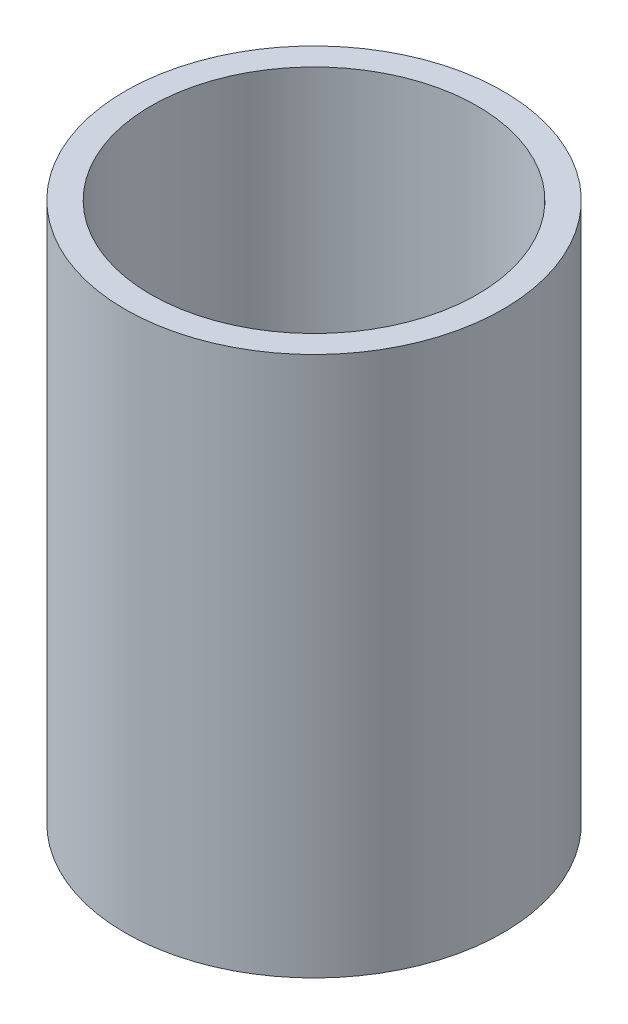
from build123d import *

# Parameters (mm, degrees)
SKETCH1_W = 6.35
SKETCH1_H = 133.35


with BuildPart() as part:
    # Sketch1 → Revolve1 (revolve)
    with BuildSketch(Plane.XY):
        with Locations((-43.4975, -21.057365567)):
            Rectangle(SKETCH1_W, SKETCH1_H)
    revolve(axis=Axis((0, 55, 0), (0, -1, 0)))


solid = part.part
